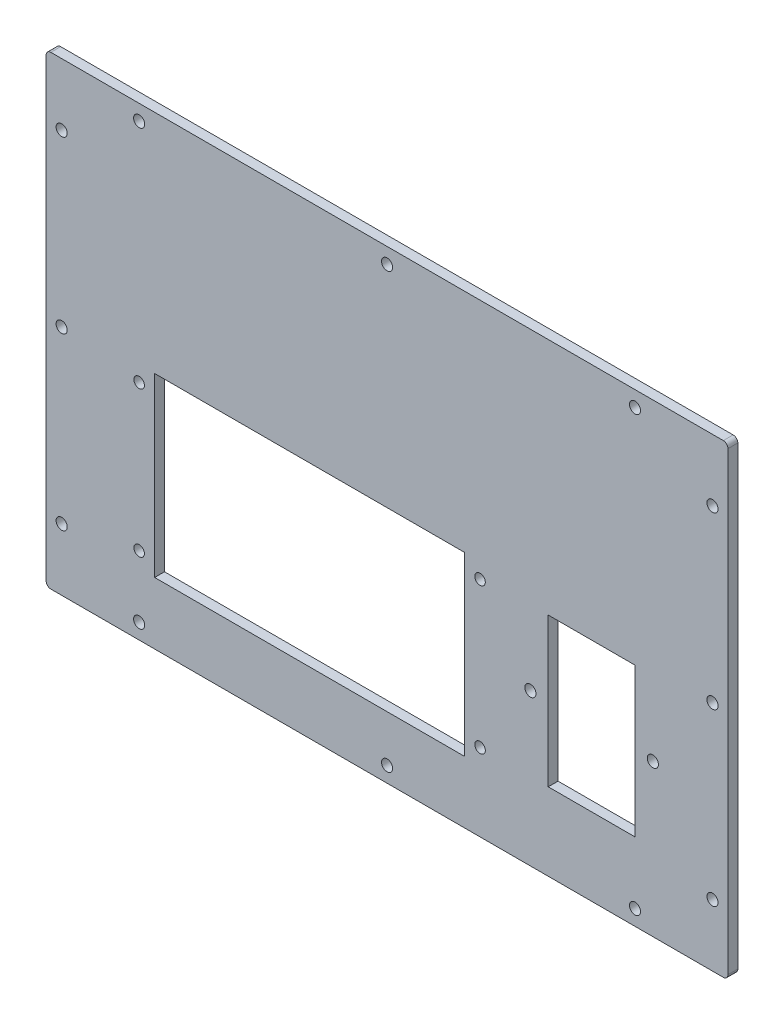
from build123d import *

# Parameters (mm, degrees)
SKETCH1_W            = 220
SKETCH1_H            = 150
BOSS_EXTRUDE1_DEPTH  = 3.175
M3_CLEARANCE_HOLE1_D = 3.6
SKETCH4_W            = 10
SKETCH4_H            = 10
BOSS_EXTRUDE2_DEPTH  = 3.175
FILLET2_R            = 1.5
SKETCH5_W            = 28
SKETCH5_H            = 48
CUT_EXTRUDE1_DEPTH   = 4.175
M3_CLEARANCE_HOLE2_D = 3.6
SKETCH8_W            = 100
SKETCH8_H            = 57
CUT_EXTRUDE2_DEPTH   = 4.175
M3_CLEARANCE_HOLE3_D = 3.4


with BuildPart() as part:
    # Sketch1 → Boss-Extrude1 (new body)
    with BuildSketch(Plane.XY):
        Rectangle(SKETCH1_W, SKETCH1_H)
    extrude(amount=BOSS_EXTRUDE1_DEPTH)

    # M3 Clearance Hole1 (through all)
    with Locations(Plane.XY.offset(3.175)):
        with Locations((0, 0), (-80, 70), (80, 70), (0, 70), (-105, 55), (-105, 0), (-105, -55), (-80, -70), (0, -70), (80, -70), (105, -55), (105, 0), (105, 55)):
            Hole(M3_CLEARANCE_HOLE1_D / 2)

    # Sketch4 → Boss-Extrude2 (add, through all)
    with BuildSketch(Plane.XY.offset(3.175)):
        Rectangle(SKETCH4_W, SKETCH4_H)
    extrude(amount=-BOSS_EXTRUDE2_DEPTH)

    # Fillet2
    fillet2_edges = [part.edges().sort_by_distance(p)[0] for p in [
        (-110, -75, 1.5875),
        (-110, 75, 1.5875),
        (110, 75, 1.5875),
        (110, -75, 1.5875),
    ]]
    fillet(fillet2_edges, radius=FILLET2_R)

    # Sketch5 → Cut-Extrude1 (cut, through all)
    with BuildSketch(Plane.XY.offset(3.175)):
        with Locations((66, -26)):
            Rectangle(SKETCH5_W, SKETCH5_H)
    extrude(amount=-CUT_EXTRUDE1_DEPTH, mode=Mode.SUBTRACT)

    # M3 Clearance Hole2 (through all)
    with Locations(Plane.XY.offset(3.175)):
        with Locations((46.25, -26), (85.75, -26)):
            Hole(M3_CLEARANCE_HOLE2_D / 2)

    # Sketch8 → Cut-Extrude2 (cut, through all)
    with BuildSketch(Plane.XY.offset(3.175)):
        with Locations((-25, -26.5)):
            Rectangle(SKETCH8_W, SKETCH8_H)
    extrude(amount=-CUT_EXTRUDE2_DEPTH, mode=Mode.SUBTRACT)

    # M3 Clearance Hole3 (through all)
    with Locations(Plane.XY.offset(3.175)):
        with Locations((-80, -3), (-80, -50), (30, -50), (30, -3)):
            Hole(M3_CLEARANCE_HOLE3_D / 2)


solid = part.part
